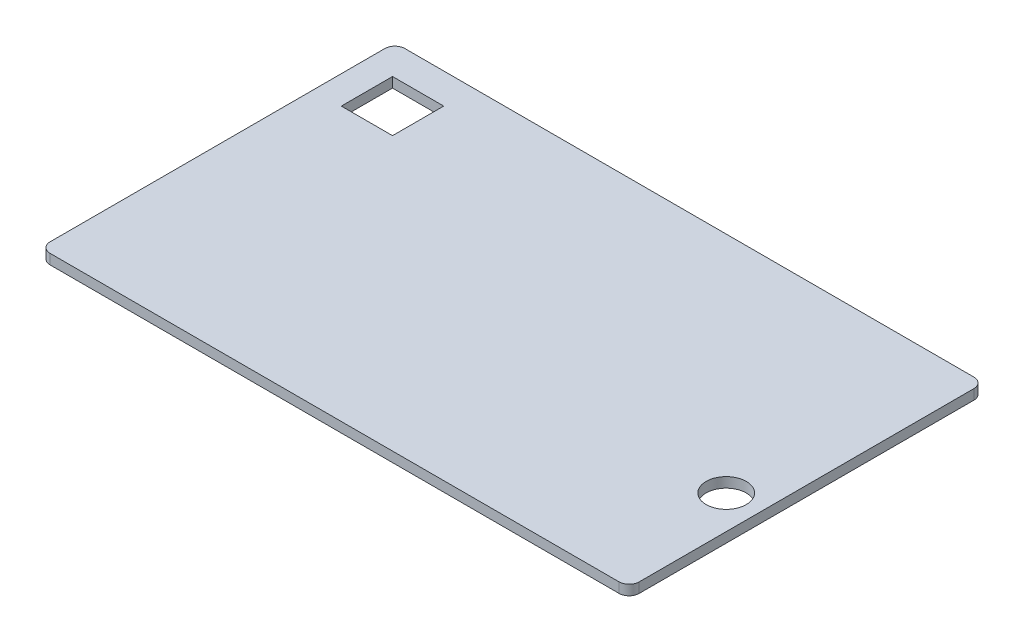
from build123d import *

# Parameters (mm, degrees)
ESQUISSE1_W             = 176
ESQUISSE1_H             = 106
BOSS_EXTRU_1_DEPTH      = 3
CONG_1_R                = 3
ESQUISSE3_R             = 6
ENL_V_MAT_EXTRU_2_DEPTH = 10
ESQUISSE4_W             = 15.3
ESQUISSE4_H             = 15.3
ENL_V_MAT_EXTRU_3_DEPTH = 10


with BuildPart() as part:
    # Esquisse1 → Boss.-Extru.1 (new body)
    with BuildSketch(Plane(origin=(0, 0, 0), x_dir=(1, 0, 0), z_dir=(0, 1, 0))):
        Rectangle(ESQUISSE1_W, ESQUISSE1_H)
    extrude(amount=BOSS_EXTRU_1_DEPTH)

    # Congé1
    cong_1_edges = [part.edges().sort_by_distance(p)[0] for p in [
        (88, 1.5, 53),
        (-88, 1.5, 53),
        (-88, 1.5, -53),
        (88, 1.5, -53),
    ]]
    fillet(cong_1_edges, radius=CONG_1_R)

    # Esquisse3 → Enlèv. mat.-Extru.2 (cut)
    with BuildSketch(Plane.XZ):
        with Locations((78, 14)):
            Circle(ESQUISSE3_R)
    extrude(amount=-ENL_V_MAT_EXTRU_2_DEPTH, mode=Mode.SUBTRACT)

    # Esquisse4 → Enlèv. mat.-Extru.3 (cut)
    with BuildSketch(Plane.XZ):
        with Locations((-71.961639113, -36.263401643)):
            Rectangle(ESQUISSE4_W, ESQUISSE4_H)
    extrude(amount=-ENL_V_MAT_EXTRU_3_DEPTH, mode=Mode.SUBTRACT)


solid = part.part
